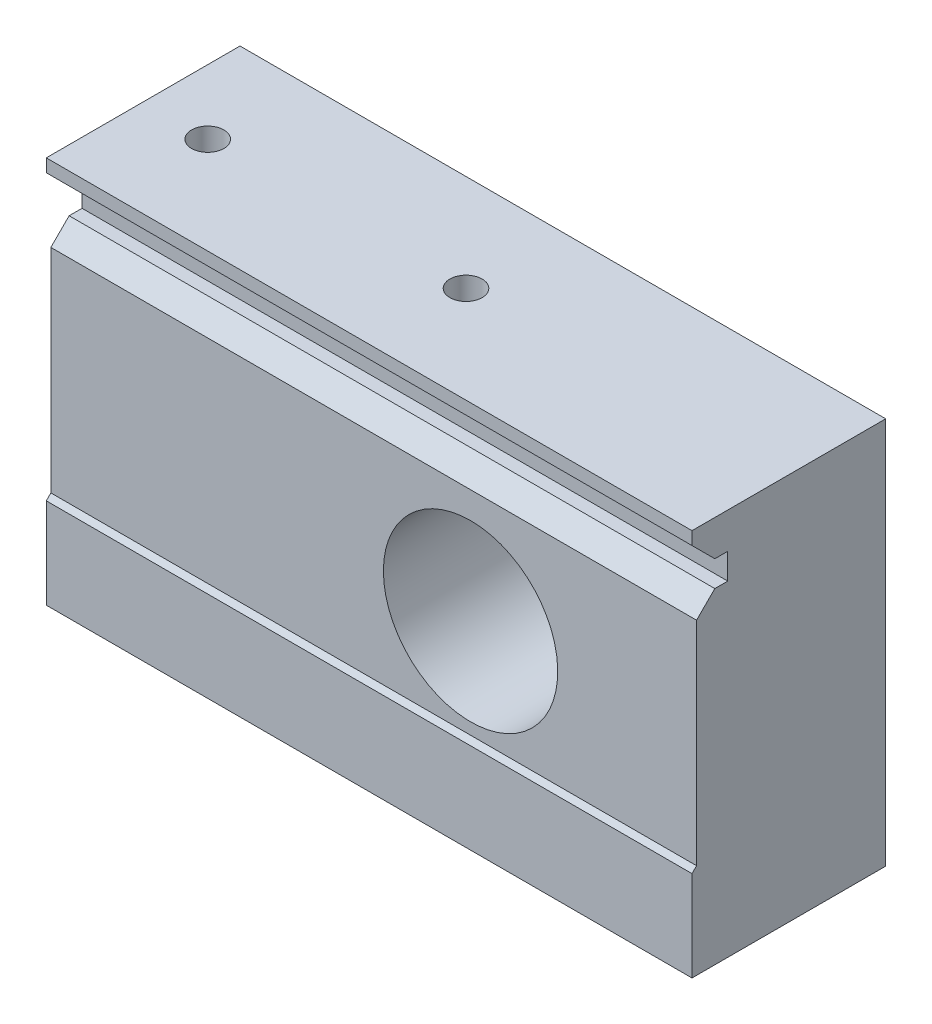
from build123d import *

# Parameters (mm, degrees)
SKETCH1_W                   = 100
SKETCH1_H                   = 60
BOSS_EXTRUDE1_DEPTH         = 30
CUT_EXTRUDE1_DEPTH          = 110
SKETCH_1_R                  = 2.5
CUT_EXTRUDE_1_DEPTH         = 10
PATTERN_LINEAR_1_COUNT      = 2
PATTERN_LINEAR_1_PITCH      = 40
PATTERN_LINEAR_1_COUNT_DIR2 = 2
PATTERN_LINEAR_1_PITCH_DIR2 = 50
SKETCH_2_R                  = 13.5
CUT_EXTRUDE_2_DEPTH         = 100


with BuildPart() as part:
    # Sketch1 → Boss-Extrude1 (new body)
    with BuildSketch(Plane.XY):
        with Locations((2.079207921, -0.485148515)):
            Rectangle(SKETCH1_W, SKETCH1_H)
    extrude(amount=BOSS_EXTRUDE1_DEPTH)

    # Sketch3 → Cut-Extrude1 (cut)
    with BuildSketch(Plane.ZY.offset(47.920792079)):
        Polygon((30, -30.485148515), (30, -16.485148515), (29.292893219, -15.778041734), (29.292893219, 17.150890454), (26.464466094, 19.979317579), (24.464466094, 19.979317579), (24.464466094, 23.979317579), (26.464466094, 23.979317579), (30, 27.514851485), (30, 29.514851485), (35.630972976, 28.601630178), (37.149112702, -26.247837132), align=None)
    extrude(amount=-CUT_EXTRUDE1_DEPTH, mode=Mode.SUBTRACT)

    # Эскиз1 → Вырез-Вытянуть1 (cut)
    with BuildSketch(Plane(origin=(0, 29.514851485, 0), x_dir=(1, 0, 0), z_dir=(0, 1, 0))):
        with Locations((2.079207921, -15)):
            Circle(SKETCH_1_R)
    cut_extrude_1 = extrude(amount=-CUT_EXTRUDE_1_DEPTH, mode=Mode.SUBTRACT)

    # Линейный массив1: Cut-Extrude 1 2 × 2
    with Locations(*[(-i * PATTERN_LINEAR_1_PITCH, -j * PATTERN_LINEAR_1_PITCH_DIR2, 0) for i in range(PATTERN_LINEAR_1_COUNT) for j in range(PATTERN_LINEAR_1_COUNT_DIR2) if (i, j) != (0, 0)]):
        add(cut_extrude_1, mode=Mode.SUBTRACT)

    # Эскиз2 → Вырез-Вытянуть2 (cut)
    with BuildSketch(Plane(origin=(0, 0, 0), x_dir=(-1, 0, 0), z_dir=(0, 0, -1))):
        with Locations((-17.079207921, -0.485148515)):
            Circle(SKETCH_2_R)
    extrude(amount=-CUT_EXTRUDE_2_DEPTH, mode=Mode.SUBTRACT)


solid = part.part
